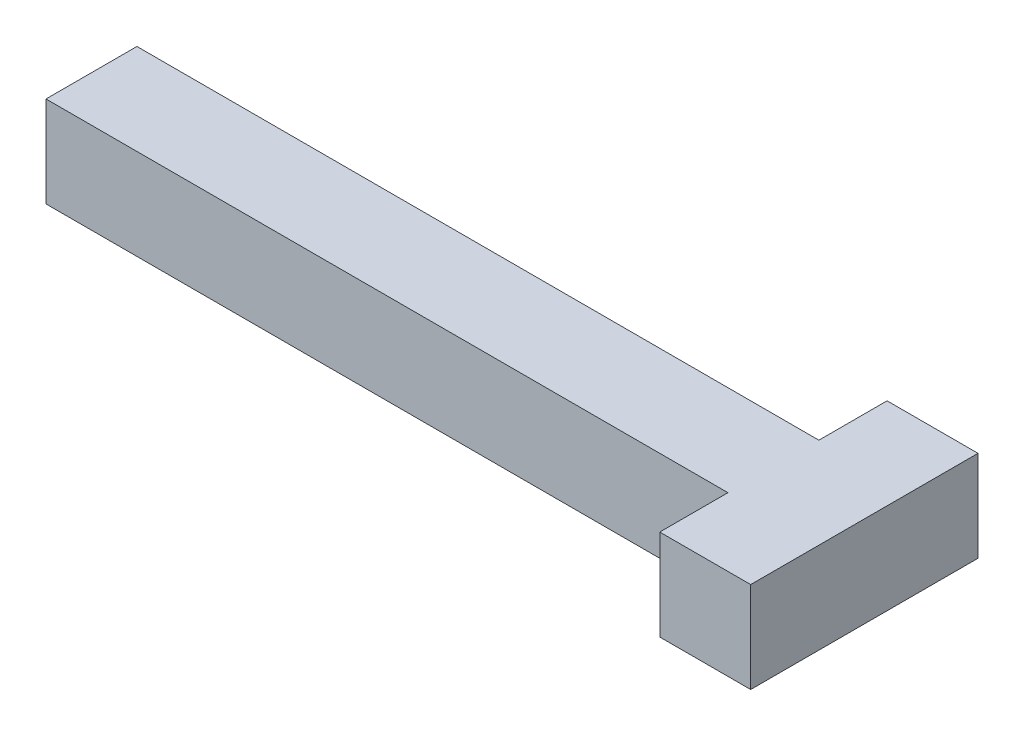
from build123d import *

# Parameters (mm, degrees)
SKETCH1_W           = 15
SKETCH1_H           = 2
BOSS_EXTRUDE1_DEPTH = 2


with BuildPart() as part:
    # Sketch1 → Boss-Extrude1 (new body)
    with BuildSketch(Plane(origin=(0, 0, 0), x_dir=(1, 0, 0), z_dir=(0, 1, 0))):
        Rectangle(SKETCH1_W, SKETCH1_H)
        Polygon((7.5, 1), (7.5, -1), (7.5, -2.5), (9.5, -2.5), (9.5, 2.5), (7.5, 2.5), align=None)
    extrude(amount=BOSS_EXTRUDE1_DEPTH)


solid = part.part
